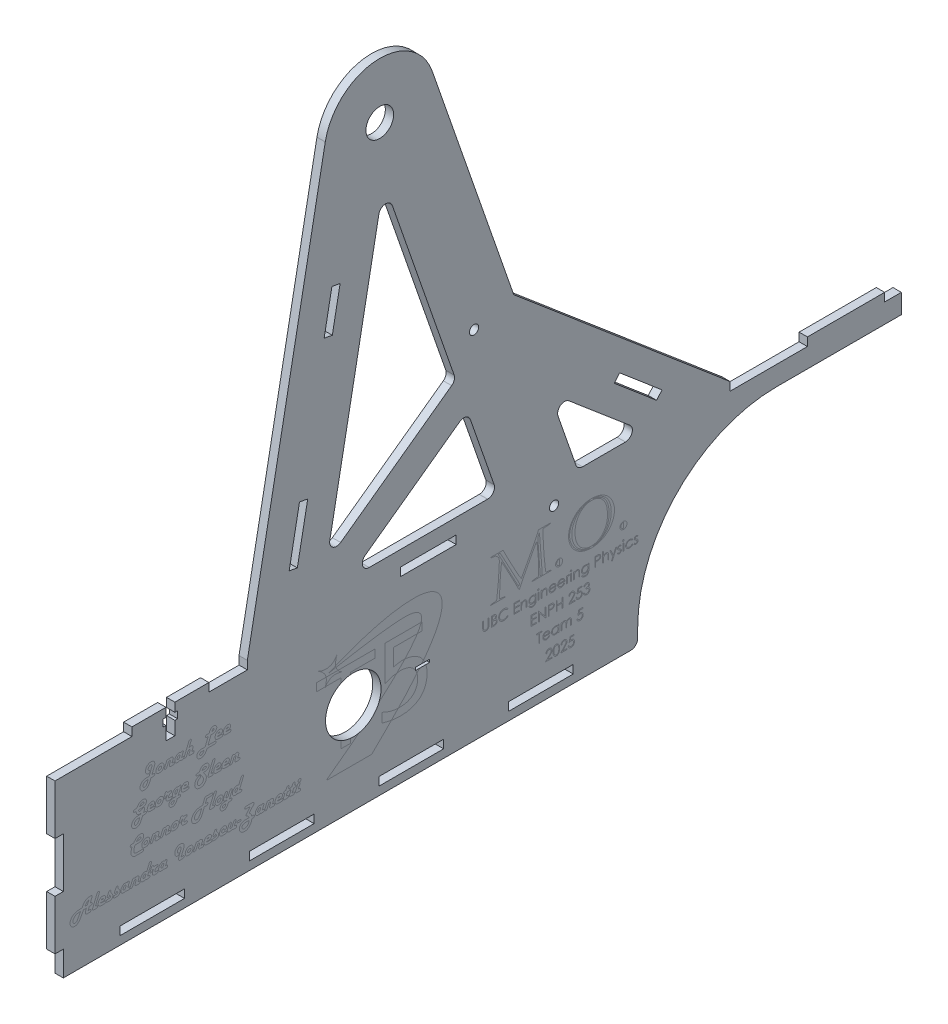
from build123d import *

# Parameters (mm, degrees)
BOSS_EXTRUDE1_DEPTH     = 3
SKETCH2_W               = 27.727272727
SKETCH2_H               = 3
SKETCH2_W_2             = 3
SKETCH2_H_2             = 18
SKETCH2_H_3             = 9
SKETCH2_W_3             = 23.343342349
SKETCH2_W_4             = 23.34334235
SKETCH2_W_5             = 6
CUT_EXTRUDE1_DEPTH      = 1
CUT_EXTRUDE1_DEPTH_BACK = 4
SKETCH3_W               = 3.2
SKETCH3_H               = 10.5
SKETCH3_W_2             = 5.2
SKETCH3_H_2             = 2.5
CUT_EXTRUDE2_DEPTH      = 1
CUT_EXTRUDE2_DEPTH_BACK = 4
FILLET1_R               = 2.5
BOSS_EXTRUDE2_DEPTH     = 3
FILLET2_R               = 2.5
SKETCH6_R               = 5
SKETCH6_R_2             = 1.65
CUT_EXTRUDE5_DEPTH      = 1
CUT_EXTRUDE5_DEPTH_BACK = 4
SKETCH8_R               = 10
SKETCH8_W               = 5
SKETCH8_H               = 1
CUT_EXTRUDE6_DEPTH      = 4
CUT_EXTRUDE6_DEPTH_BACK = 1
SKETCH9_W               = 20
SKETCH9_H               = 3
CUT_EXTRUDE7_DEPTH      = 4
CUT_EXTRUDE7_DEPTH_BACK = 1
SKETCH10_W              = 27.840909091
SKETCH10_H              = 3
CUT_EXTRUDE8_DEPTH      = 4
CUT_EXTRUDE8_DEPTH_BACK = 1


with BuildPart() as part:
    # Sketch1 → Boss-Extrude1 (new body)
    with BuildSketch(Plane(origin=(0, 0, 0), x_dir=(0, 0, -1), z_dir=(1, 0, 0))):
        with BuildLine():
            Line((-152.5, 33), (152.5, 33))
            Line((152.5, 33), (152.5, 23))
            Line((152.5, 23), (107.5, 23))
            ThreePointArc((107.5, 23), (72.144660941, 8.355339059), (57.5, -27))
            Line((57.5, -27), (57.5, -33))
            Line((57.5, -33), (-152.5, -33))
            Line((-152.5, -33), (-152.5, 33))
        make_face()
    extrude(amount=BOSS_EXTRUDE1_DEPTH)

    # Sketch2 → Cut-Extrude1 (cut, two sides)
    with BuildSketch(Plane(origin=(3, 0, 0), x_dir=(0, 0, -1), z_dir=(1, 0, 0))) as cut_extrude1_sk:
        with Locations((-138.636363636, 31.5)):
            Rectangle(SKETCH2_W, SKETCH2_H)
        with Locations((-83.181818182, 31.5)):
            Rectangle(SKETCH2_W, SKETCH2_H)
        with Locations((-27.727272728, 31.5)):
            Rectangle(SKETCH2_W, SKETCH2_H)
        with Locations((-151, 3)):
            Rectangle(SKETCH2_W_2, SKETCH2_H_2)
        with Locations((-151, -28.5)):
            Rectangle(SKETCH2_W_2, SKETCH2_H_3)
        with Locations((-117.484986475, -28.5)):
            Rectangle(SKETCH2_W_3, SKETCH2_H)
        with Locations((-70.798301777, -28.5)):
            Rectangle(SKETCH2_W_3, SKETCH2_H)
        with Locations((22.575067622, -28.5)):
            Rectangle(SKETCH2_W_4, SKETCH2_H)
        with Locations((149.5, 31.5)):
            Rectangle(SKETCH2_W_5, SKETCH2_H)
        with Locations((-24.111617078, -28.5)):
            Rectangle(SKETCH2_W_3, SKETCH2_H)
    extrude(amount=CUT_EXTRUDE1_DEPTH, mode=Mode.SUBTRACT)
    extrude(cut_extrude1_sk.sketch, amount=-CUT_EXTRUDE1_DEPTH_BACK, mode=Mode.SUBTRACT)

    # Sketch3 → Cut-Extrude2 (cut, two sides)
    with BuildSketch(Plane(origin=(3, 0, 0), x_dir=(0, 0, -1), z_dir=(1, 0, 0))) as cut_extrude2_sk:
        with Locations((-110.909090909, 27.75)):
            Rectangle(SKETCH3_W, SKETCH3_H)
        with Locations((-110.909090909, 28.575)):
            Rectangle(SKETCH3_W_2, SKETCH3_H_2)
    extrude(amount=CUT_EXTRUDE2_DEPTH, mode=Mode.SUBTRACT)
    extrude(cut_extrude2_sk.sketch, amount=-CUT_EXTRUDE2_DEPTH_BACK, mode=Mode.SUBTRACT)

    # Fillet1
    fillet1_edges = [part.edges().sort_by_distance(p)[0] for p in [
        (1.5, -33, -57.5),
    ]]
    fillet(fillet1_edges, radius=FILLET1_R)

    # Sketch4 → Boss-Extrude2 (add)
    with BuildSketch(Plane(origin=(0, 0, 0), x_dir=(0, 0, -1), z_dir=(1, 0, 0))):
        with BuildLine():
            Line((-83.181818182, 33), (-83.181818182, 30))
            Line((-83.181818182, 30), (35.818181818, 30))
            Line((35.818181818, 30), (35.818181818, 33))
            Line((35.818181818, 33), (25.753026775, 61.931534749))
            Line((25.753026775, 61.931534749), (59.886459158, 33))
            Line((59.886459158, 33), (90.818181818, 33))
            Line((90.818181818, 33), (12.817635516, 99.113348651))
            Line((12.817635516, 99.113348651), (-16.565017269, 183.571584658))
            ThreePointArc((-16.565017269, 183.571584658), (-36.922973482, 196.946020133), (-55.102803407, 180.73442893))
            Line((-55.102803407, 180.73442893), (-83.181818182, 33))
        make_face()
        Polygon((-54.643252411, 49.263022537), (-34.033564648, 157.698467174), (-8.047004759, 83.002045982), align=None, mode=Mode.SUBTRACT)
        Polygon((-3.929894771, 71.167721507), (6.913219914, 40), (-46.974972009, 40), align=None, mode=Mode.SUBTRACT)
    extrude(amount=BOSS_EXTRUDE2_DEPTH)

    # Fillet2
    fillet2_edges = [part.edges().sort_by_distance(p)[0] for p in [
        (1.5, 33, -59.886459158),
        (1.5, 61.931534749, -25.753026775),
        (1.5, 33, -35.818181818),
        (1.5, 40, -6.913219914),
        (1.5, 71.167721507, 3.929894771),
        (1.5, 40, 46.974972009),
        (1.5, 49.263022537, 54.643252411),
        (1.5, 83.002045982, 8.047004759),
        (1.5, 157.698467174, 34.033564648),
    ]]
    fillet(fillet2_edges, radius=FILLET2_R)

    # Sketch6 → Cut-Extrude5 (cut, two sides)
    with BuildSketch(Plane(origin=(3, 0, 0), x_dir=(0, 0, -1), z_dir=(1, 0, 0))) as cut_extrude5_sk:
        with Locations((-35.454545455, 177)):
            Circle(SKETCH6_R)
        with Locations((-1.492946709, 95.333591431)):
            Circle(SKETCH6_R_2)
        with Locations((27.342535354, 25.993797473)):
            Circle(SKETCH6_R_2)
    extrude(amount=CUT_EXTRUDE5_DEPTH, mode=Mode.SUBTRACT)
    extrude(cut_extrude5_sk.sketch, amount=-CUT_EXTRUDE5_DEPTH_BACK, mode=Mode.SUBTRACT)

    # Sketch8 → Cut-Extrude6 (cut, two sides)
    with BuildSketch(Plane(origin=(0, 0, 0), x_dir=(0, 0, -1), z_dir=(1, 0, 0))) as cut_extrude6_sk:
        with Locations((-45, 0)):
            Circle(SKETCH8_R)
        with Locations((-20, 0)):
            Rectangle(SKETCH8_W, SKETCH8_H)
    extrude(amount=CUT_EXTRUDE6_DEPTH, mode=Mode.SUBTRACT)
    extrude(cut_extrude6_sk.sketch, amount=-CUT_EXTRUDE6_DEPTH_BACK, mode=Mode.SUBTRACT)

    # Sketch9 → Cut-Extrude7 (cut, two sides)
    with BuildSketch(Plane(origin=(0, 0, 0), x_dir=(0, 0, -1), z_dir=(1, 0, 0))) as cut_extrude7_sk:
        Polygon((-68.111670983, 53.378521315), (-64.377242053, 73.026779267), (-61.43000336, 72.466614928), (-65.16443229, 52.818356975), align=None)
        Polygon((-55.507973344, 119.691391905), (-52.707151647, 134.427585369), (-49.759912954, 133.867421029), (-52.560734651, 119.131227565), align=None)
        Polygon((64.311409407, 40.391956194), (49.054577079, 53.32366402), (50.994333253, 55.612188869), (66.251165581, 42.680481043), align=None)
        with Locations((-17.931502251, 33)):
            Rectangle(SKETCH9_W, SKETCH9_H)
    extrude(amount=CUT_EXTRUDE7_DEPTH, mode=Mode.SUBTRACT)
    extrude(cut_extrude7_sk.sketch, amount=-CUT_EXTRUDE7_DEPTH_BACK, mode=Mode.SUBTRACT)

    # Sketch10 → Cut-Extrude8 (cut, two sides)
    with BuildSketch(Plane(origin=(0, 0, 0), x_dir=(0, 0, -1), z_dir=(1, 0, 0))) as cut_extrude8_sk:
        with Locations((104.738636364, 31.5)):
            Rectangle(SKETCH10_W, SKETCH10_H)
    extrude(amount=CUT_EXTRUDE8_DEPTH, mode=Mode.SUBTRACT)
    extrude(cut_extrude8_sk.sketch, amount=-CUT_EXTRUDE8_DEPTH_BACK, mode=Mode.SUBTRACT)


solid = part.part
